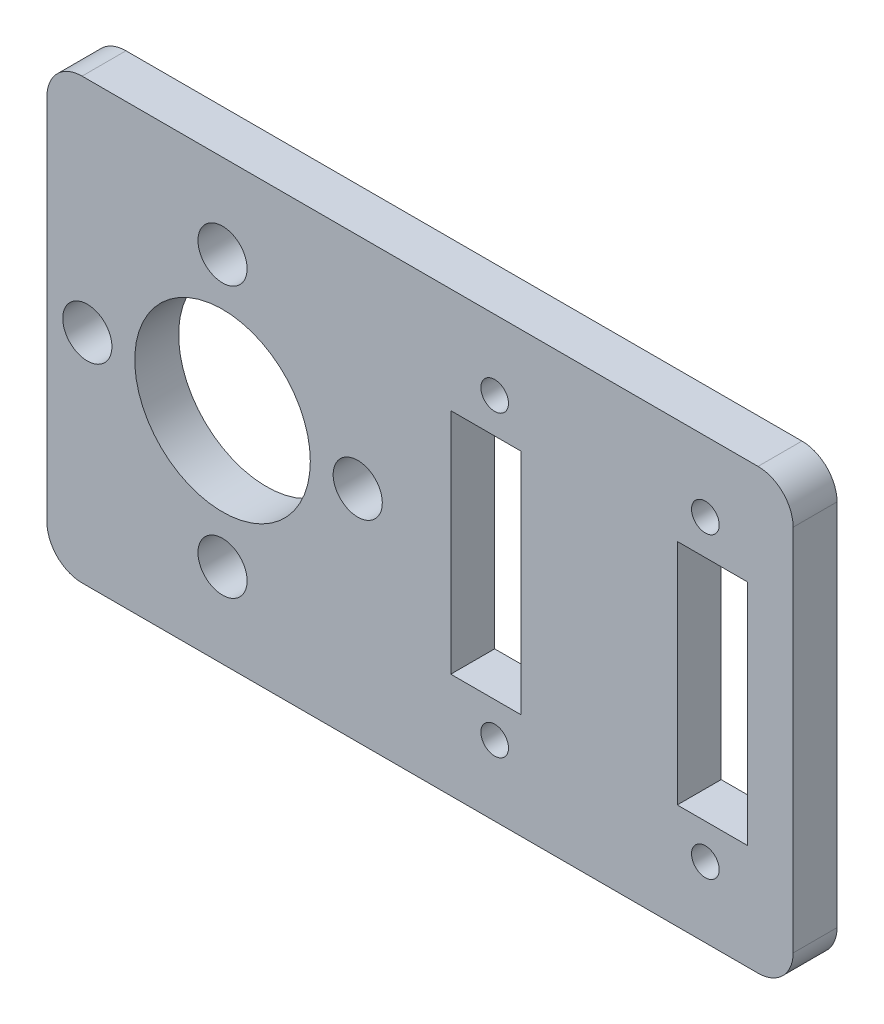
from build123d import *

# Parameters (mm, degrees)
SKETCH2_W           = 53.975
SKETCH2_H           = 31.75
SKETCH2_R           = 1
SKETCH2_W_2         = 5.08
SKETCH2_H_2         = 16.51
BOSS_EXTRUDE1_DEPTH = 3.175
SKETCH3_R           = 6.35
CUT_EXTRUDE1_DEPTH  = 3.175
SKETCH4_R           = 1.778
CUT_EXTRUDE2_DEPTH  = 3.175
CIRPATTERN1_COUNT   = 4
FILLET1_R           = 2.54


with BuildPart() as part:
    # Sketch2 → Boss-Extrude1 (new body)
    with BuildSketch(Plane.XY):
        with Locations((26.9875, 15.875)):
            Rectangle(SKETCH2_W, SKETCH2_H)
        with Locations((32.385, 26.67)):
            Circle(SKETCH2_R, mode=Mode.SUBTRACT)
        with Locations((47.625, 26.67)):
            Circle(SKETCH2_R, mode=Mode.SUBTRACT)
        with Locations((32.385, 5.08)):
            Circle(SKETCH2_R, mode=Mode.SUBTRACT)
        with Locations((47.625, 5.08)):
            Circle(SKETCH2_R, mode=Mode.SUBTRACT)
        with Locations((31.75, 15.875)):
            Rectangle(SKETCH2_W_2, SKETCH2_H_2, mode=Mode.SUBTRACT)
        with Locations((48.133, 15.875)):
            Rectangle(SKETCH2_W_2, SKETCH2_H_2, mode=Mode.SUBTRACT)
    extrude(amount=BOSS_EXTRUDE1_DEPTH)

    # Sketch3 → Cut-Extrude1 (cut)
    with BuildSketch(Plane.XY.offset(3.175)):
        with Locations((12.7, 15.875)):
            Circle(SKETCH3_R)
    extrude(amount=-CUT_EXTRUDE1_DEPTH, mode=Mode.SUBTRACT)

    # Sketch4 → Cut-Extrude2 (cut)
    with BuildSketch(Plane.XY.offset(3.175)):
        with Locations((12.7, 25.654)):
            Circle(SKETCH4_R)
    cut_extrude2 = extrude(amount=-CUT_EXTRUDE2_DEPTH, mode=Mode.SUBTRACT)

    # CirPattern1: Cut-Extrude2 ×4 about axis
    cirpattern1_axis = Axis((12.7, 15.875, 0), (0, 0, 1))
    for i in range(1, CIRPATTERN1_COUNT):
        add(cut_extrude2.rotate(cirpattern1_axis, i * 360 / CIRPATTERN1_COUNT), mode=Mode.SUBTRACT)

    # Fillet1
    fillet1_edges = [part.edges().sort_by_distance(p)[0] for p in [
        (0, 31.75, 1.5875),
        (53.975, 31.75, 1.5875),
        (53.975, 0, 1.5875),
        (0, 0, 1.5875),
    ]]
    fillet(fillet1_edges, radius=FILLET1_R)


solid = part.part
